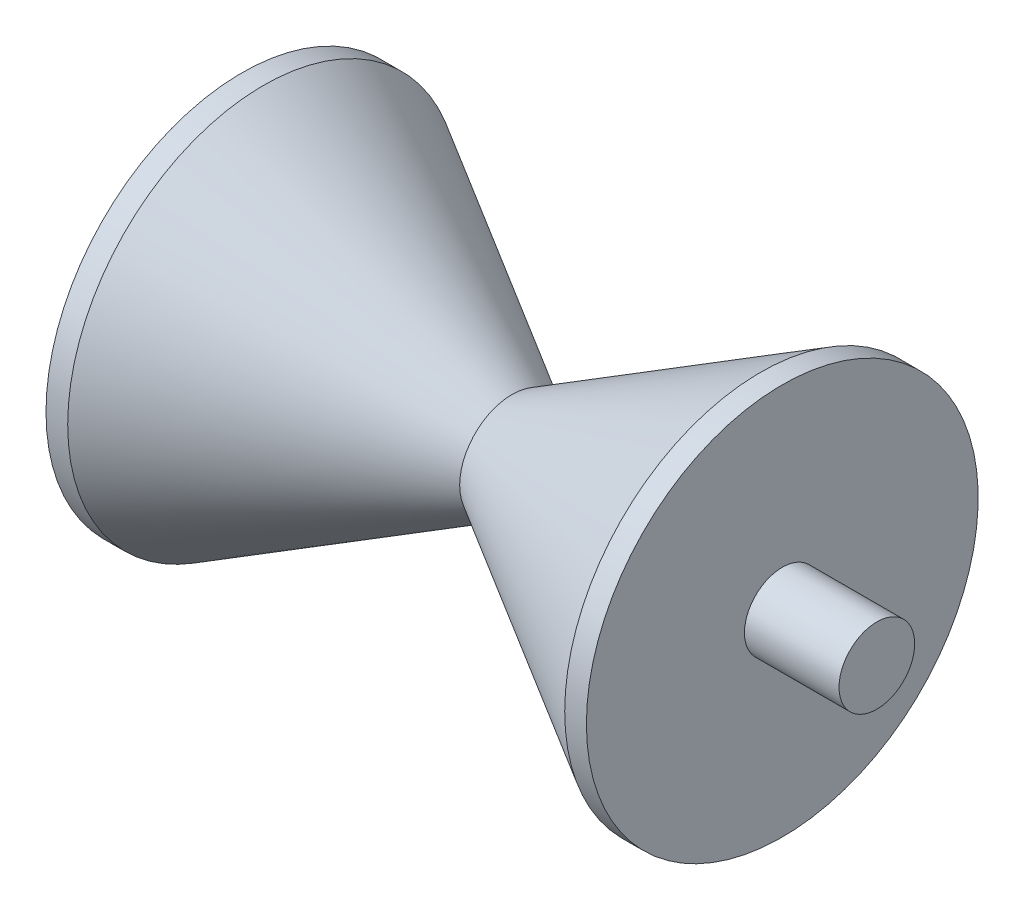
from build123d import *


with BuildPart() as part:
    # Sketch1 → Revolve1 (revolve)
    with BuildSketch(Plane.XY):
        Polygon((0, 0), (0, 0.7), (1.75, 0.7), (1.75, 3.625), (2.151405106, 3.625), (6.75, 0.97), (11.348594894, 3.625), (11.75, 3.625), (11.75, 0.7), (13.5, 0.7), (13.5, 0), align=None)
    revolve(axis=Axis((0, 0, 0), (1, 0, 0)))


solid = part.part
